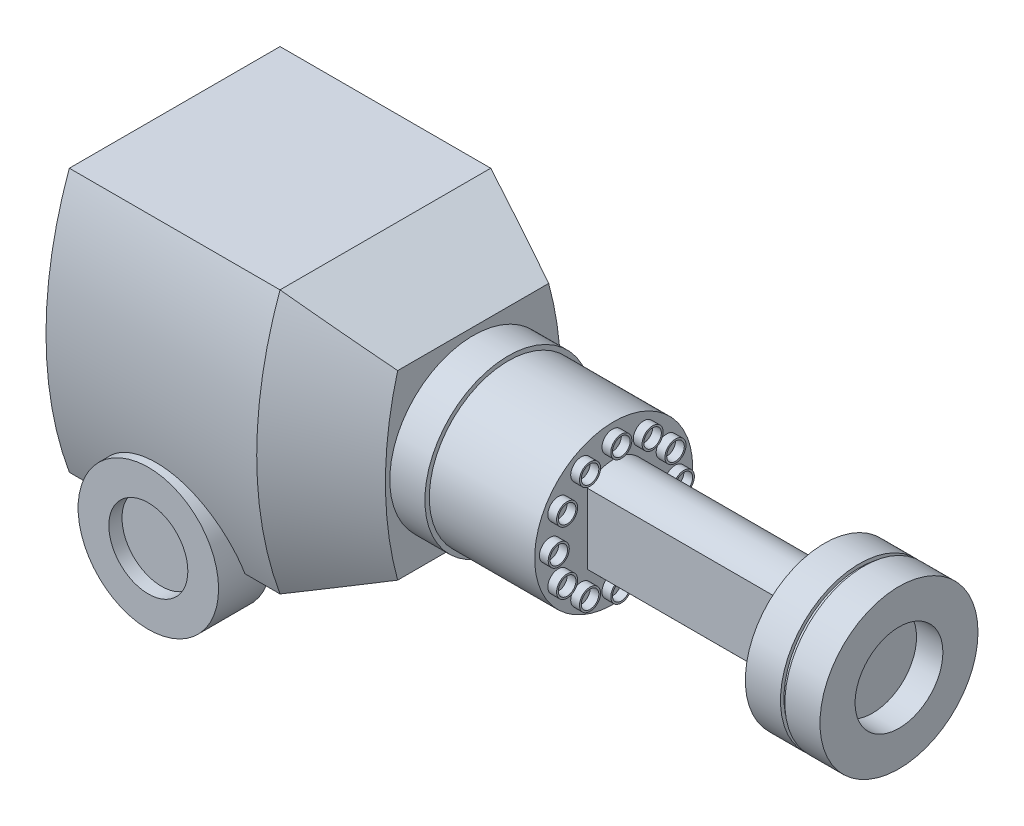
from build123d import *

# Parameters (mm, degrees)
BOSS_EXTRUDE1_DEPTH  = 30.48
BOSS_EXTRUDE2_DEPTH  = 12.7
BOSS_EXTRUDE2_DRAFT  = 25
SKETCH9_R            = 12.065
BOSS_EXTRUDE3_DEPTH  = 5.08
SKETCH10_R           = 11.43
BOSS_EXTRUDE4_DEPTH  = 15.24
SKETCH12_R           = 1.524
SKETCH12_R_2         = 1.27
BOSS_EXTRUDE6_DEPTH  = 1.27
CIRPATTERN2_COUNT    = 12
BOSS_EXTRUDE7_DEPTH  = 30.48
SKETCH14_R           = 11.43
BOSS_EXTRUDE8_DEPTH  = 5.08
SKETCH15_R           = 10.922
BOSS_EXTRUDE9_DEPTH  = 0.635
SKETCH16_R           = 11.43
BOSS_EXTRUDE10_DEPTH = 5.08
SKETCH17_R           = 10.16
BOSS_EXTRUDE14_DEPTH = 3.81
BOSS_EXTRUDE15_DEPTH = 12.7
BOSS_EXTRUDE16_DEPTH = 8.89
CUT_EXTRUDE1_DEPTH   = 8.89
SKETCH22_R           = 6.35
CUT_EXTRUDE2_DEPTH   = 3.81
SKETCH23_R           = 5.715
CUT_EXTRUDE4_DEPTH   = 1.905


with BuildPart() as part:
    # Sketch2 → Boss-Extrude1 (new body)
    with BuildSketch(Plane(origin=(0, 0, 0), x_dir=(0, 0, -1), z_dir=(1, 0, 0))):
        with BuildLine():
            Line((-15.24, 19.05), (15.24, 19.05))
            ThreePointArc((15.24, 19.05), (18.613103307, 0), (15.24, -19.05))
            Line((15.24, -19.05), (-15.24, -19.05))
            ThreePointArc((-15.24, -19.05), (-18.613103307, 0), (-15.24, 19.05))
        make_face()
    extrude(amount=BOSS_EXTRUDE1_DEPTH)


with BuildPart() as boss_extrude2_tool:
    # Sketch8 → Boss-Extrude2 (with draft: the straight prism first)
    with BuildSketch(Plane(origin=(30.48, 0, 0), x_dir=(0, 0, -1), z_dir=(1, 0, 0))):
        with BuildLine():
            Line((15.24, 19.05), (-15.24, 19.05))
            ThreePointArc((-15.24, 19.05), (-18.613103307, 0), (-15.24, -19.05))
            Line((-15.24, -19.05), (15.24, -19.05))
            ThreePointArc((15.24, -19.05), (18.613103307, 0), (15.24, 19.05))
        make_face()
    extrude(amount=BOSS_EXTRUDE2_DEPTH)
    # Boss-Extrude2: the draft: its side faces are tilted about the plane it starts from
    boss_extrude2_sides = [boss_extrude2_tool.faces().sort_by_distance(p)[0] for p in [
        (36.83, 19.05, 0),
        (36.83, 0, 18.613103307),
        (36.83, -19.05, 0),
        (36.83, 0, -18.613103307),
    ]]
    draft(boss_extrude2_sides, Plane(origin=(30.48, 0, 0), x_dir=(0, 0, -1), z_dir=(1, 0, 0)), BOSS_EXTRUDE2_DRAFT)


with BuildPart() as part_1:
    add(part.part)

    # Boss-Extrude2: add boss_extrude2_tool
    add(boss_extrude2_tool.part)

    # Sketch9 → Boss-Extrude3 (add)
    with BuildSketch(Plane(origin=(43.18, 0, 0), x_dir=(0, 0, -1), z_dir=(1, 0, 0))):
        Circle(SKETCH9_R)
    extrude(amount=BOSS_EXTRUDE3_DEPTH)

    # Sketch10 → Boss-Extrude4 (add)
    with BuildSketch(Plane(origin=(48.26, 0, 0), x_dir=(0, 0, -1), z_dir=(1, 0, 0))):
        Circle(SKETCH10_R)
    extrude(amount=BOSS_EXTRUDE4_DEPTH)

    # Sketch12 → Boss-Extrude6 (add)
    with BuildSketch(Plane(origin=(63.5, 0, 0), x_dir=(0, 0, -1), z_dir=(1, 0, 0))):
        with Locations((8.89, 0)):
            Circle(SKETCH12_R)
        with Locations((8.89, 0)):
            Circle(SKETCH12_R_2, mode=Mode.SUBTRACT)
    boss_extrude6 = extrude(amount=BOSS_EXTRUDE6_DEPTH)

    # CirPattern2: Boss-Extrude6 ×12 about axis
    cirpattern2_axis = Axis((0, 0, 0.160904977), (1, 0, 0))
    for i in range(1, CIRPATTERN2_COUNT):
        add(boss_extrude6.rotate(cirpattern2_axis, i * 360 / CIRPATTERN2_COUNT))

    # Sketch13 → Boss-Extrude7 (add)
    with BuildSketch(Plane(origin=(63.5, 0, 0), x_dir=(0, 0, -1), z_dir=(1, 0, 0))):
        with BuildLine():
            Line((3.81, 5.000460116), (3.81, -5.159539884))
            ThreePointArc((3.81, -5.159539884), (0, -6.879435719), (-3.81, -5.159539884))
            Line((-3.81, -5.159539884), (-3.81, 5.000460116))
            ThreePointArc((-3.81, 5.000460116), (0, 6.720355951), (3.81, 5.000460116))
        make_face()
    extrude(amount=BOSS_EXTRUDE7_DEPTH)

    # Sketch14 → Boss-Extrude8 (add)
    with BuildSketch(Plane(origin=(93.98, 0, 0), x_dir=(0, 0, -1), z_dir=(1, 0, 0))):
        Circle(SKETCH14_R)
    extrude(amount=BOSS_EXTRUDE8_DEPTH)

    # Sketch15 → Boss-Extrude9 (add)
    with BuildSketch(Plane(origin=(99.06, 0, 0), x_dir=(0, 0, -1), z_dir=(1, 0, 0))):
        Circle(SKETCH15_R)
    extrude(amount=BOSS_EXTRUDE9_DEPTH)

    # Sketch16 → Boss-Extrude10 (add)
    with BuildSketch(Plane(origin=(99.695, 0, 0), x_dir=(0, 0, -1), z_dir=(1, 0, 0))):
        Circle(SKETCH16_R)
    extrude(amount=BOSS_EXTRUDE10_DEPTH)

    # Sketch17 → Boss-Extrude14 (add, symmetric)
    with BuildSketch(Plane.XY.offset(15.24)):
        with Locations((15.24, -19.05)):
            Circle(SKETCH17_R)
    extrude(amount=BOSS_EXTRUDE14_DEPTH, both=True)

    # Sketch19 → Boss-Extrude15 (add)
    with BuildSketch(Plane(origin=(0, 0, 11.43), x_dir=(-1, 0, 0), z_dir=(0, 0, -1))):
        with BuildLine():
            Line((-19.418499269, -19.05), (-10.527211987, -19.05))
            Line((-10.527211987, -19.05), (-10.527211987, -26.67))
            ThreePointArc((-10.527211987, -26.67), (-14.972855628, -28.51144589), (-19.418499269, -26.67))
            Line((-19.418499269, -26.67), (-19.418499269, -19.05))
        make_face()
    extrude(amount=BOSS_EXTRUDE15_DEPTH)

    # Sketch20 → Boss-Extrude16 (add)
    with BuildSketch(Plane(origin=(19.418499269, 0, 0), x_dir=(0, 0, -1), z_dir=(1, 0, 0))):
        with BuildLine():
            Line((1.27, -19.05), (12.926323027, -19.05))
            ThreePointArc((12.926323027, -19.05), (8.330590053, -25.484349932), (1.27, -29.043800552))
            Line((1.27, -29.043800552), (1.27, -19.05))
        make_face()
    extrude(amount=-BOSS_EXTRUDE16_DEPTH)

    # Sketch21 → Cut-Extrude1 (cut)
    with BuildSketch(Plane.XY.offset(-1.27)):
        with BuildLine():
            Line((10.528499269, -26.671286909), (10.528499269, -29.043800552))
            Line((10.528499269, -29.043800552), (19.418499269, -29.043800552))
            Line((19.418499269, -29.043800552), (19.418499269, -26.67))
            ThreePointArc((19.418499269, -26.67), (14.973765742, -28.511445824), (10.528499269, -26.671286909))
        make_face()
    extrude(amount=-CUT_EXTRUDE1_DEPTH, mode=Mode.SUBTRACT)

    # Sketch22 → Cut-Extrude2 (cut)
    with BuildSketch(Plane(origin=(104.775, 0, 0), x_dir=(0, 0, -1), z_dir=(1, 0, 0))):
        Circle(SKETCH22_R)
    extrude(amount=-CUT_EXTRUDE2_DEPTH, mode=Mode.SUBTRACT)

    # Sketch23 → Cut-Extrude4 (cut)
    with BuildSketch(Plane.XY.offset(19.05)):
        with Locations((15.24, -19.05)):
            Circle(SKETCH23_R)
    extrude(amount=-CUT_EXTRUDE4_DEPTH, mode=Mode.SUBTRACT)


solid = part_1.part
